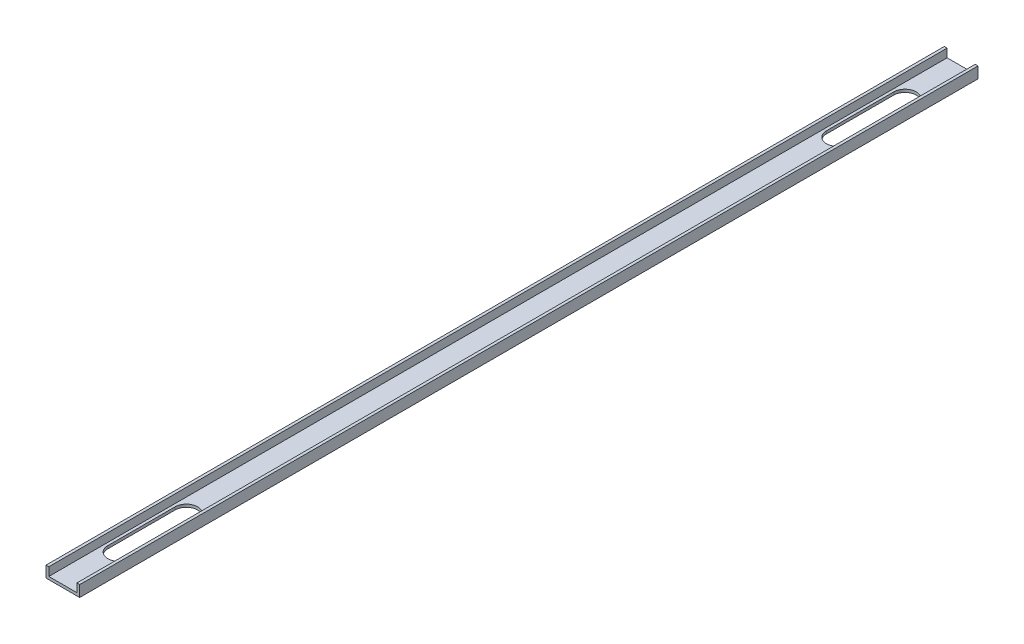
from build123d import *

# Parameters (mm, degrees)
EXTRUDE_F_DEPTH    = 1016
CUT_EXTRUDE1_DEPTH = 3.175


with BuildPart() as part:
    # Sketch1 → Extrude f (new body)
    with BuildSketch(Plane.XY):
        Polygon((3.175, 3.175), (3.175, 12.7), (0, 12.7), (0, 0), (38.1, 0), (38.1, 12.7), (34.925, 12.7), (34.925, 3.175), align=None)
    extrude(amount=EXTRUDE_F_DEPTH)

    # Sketch2 → Cut-Extrude1 (cut)
    with BuildSketch(Plane(origin=(0, 3.175, 0), x_dir=(1, 0, 0), z_dir=(0, 1, 0))):
        with BuildLine():
            Line((6.35, -952.5), (6.35, -876.3))
            ThreePointArc((6.35, -876.3), (19.05, -863.6), (31.75, -876.3))
            Line((31.75, -876.3), (31.75, -952.5))
            ThreePointArc((31.75, -952.5), (19.05, -965.2), (6.35, -952.5))
        make_face()
    cut_extrude1 = extrude(amount=-CUT_EXTRUDE1_DEPTH, mode=Mode.SUBTRACT)

    # Mirror1: Cut-Extrude1 across plane
    add(cut_extrude1.mirror(Plane.XY.offset(508)), mode=Mode.SUBTRACT)


solid = part.part
